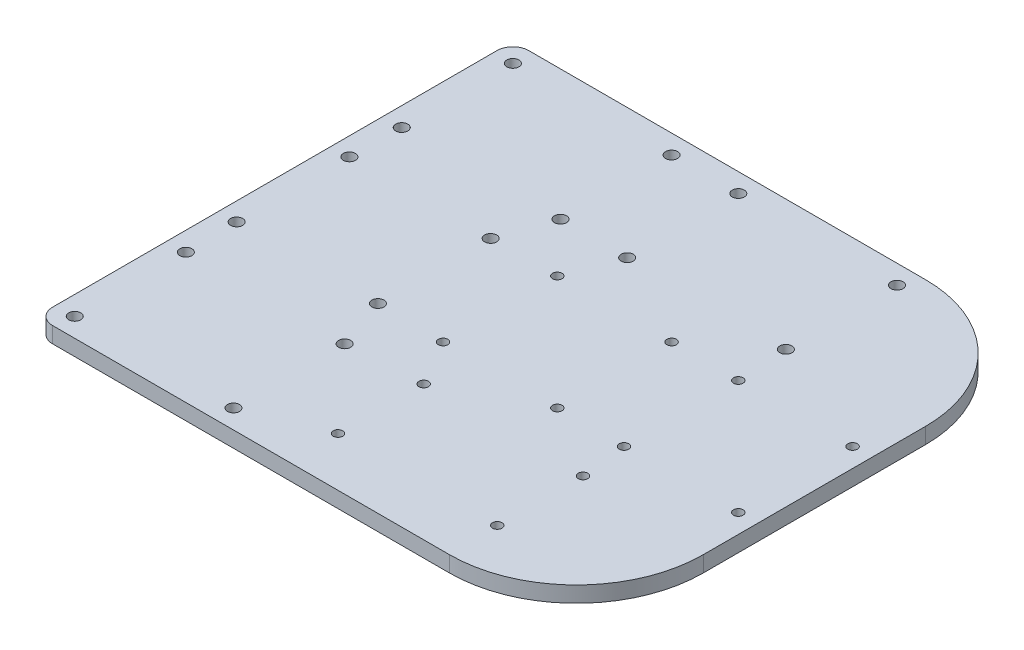
from build123d import *

# Parameters (mm, degrees)
SKETCH_1_W      = 170
SKETCH_1_H      = 150
SKETCH_1_R      = 1.5
SKETCH_1_R_2    = 1.9
EXTRUDE_1_DEPTH = 5
FILLET_1_R      = 5
FILLET_2_R      = 40


with BuildPart() as part:
    # 草图1 → 凸台-拉伸1 (new body)
    with BuildSketch(Plane(origin=(0, 0, 0), x_dir=(1, 0, 0), z_dir=(0, 1, 0))):
        with Locations((-4, 0)):
            Rectangle(SKETCH_1_W, SKETCH_1_H)
        with Locations((75, 18)):
            Circle(SKETCH_1_R, mode=Mode.SUBTRACT)
        with Locations((18, 18)):
            Circle(SKETCH_1_R, mode=Mode.SUBTRACT)
        with Locations((-83.25, 17.75)):
            Circle(SKETCH_1_R_2, mode=Mode.SUBTRACT)
        with Locations((-9.58, -59.5)):
            Circle(SKETCH_1_R, mode=Mode.SUBTRACT)
        with Locations((-83, 34)):
            Circle(SKETCH_1_R_2, mode=Mode.SUBTRACT)
        with Locations((-83, 69)):
            Circle(SKETCH_1_R_2, mode=Mode.SUBTRACT)
        with Locations((-33, 34)):
            Circle(SKETCH_1_R_2, mode=Mode.SUBTRACT)
        with Locations((-33, 69)):
            Circle(SKETCH_1_R_2, mode=Mode.SUBTRACT)
        with Locations((-12, 34)):
            Circle(SKETCH_1_R_2, mode=Mode.SUBTRACT)
        with Locations((-12, 69)):
            Circle(SKETCH_1_R_2, mode=Mode.SUBTRACT)
        with Locations((38, 69)):
            Circle(SKETCH_1_R_2, mode=Mode.SUBTRACT)
        with Locations((38, 34)):
            Circle(SKETCH_1_R_2, mode=Mode.SUBTRACT)
        with Locations((-38.75, 17.75)):
            Circle(SKETCH_1_R_2, mode=Mode.SUBTRACT)
        with Locations((-18, 18)):
            Circle(SKETCH_1_R, mode=Mode.SUBTRACT)
        with Locations((39, 18)):
            Circle(SKETCH_1_R, mode=Mode.SUBTRACT)
        with Locations((75, -18)):
            Circle(SKETCH_1_R, mode=Mode.SUBTRACT)
        with Locations((39, -18)):
            Circle(SKETCH_1_R, mode=Mode.SUBTRACT)
        with Locations((18, -18)):
            Circle(SKETCH_1_R, mode=Mode.SUBTRACT)
        with Locations((-18, -18)):
            Circle(SKETCH_1_R, mode=Mode.SUBTRACT)
        with Locations((-83, -69)):
            Circle(SKETCH_1_R_2, mode=Mode.SUBTRACT)
        with Locations((-33, -69)):
            Circle(SKETCH_1_R_2, mode=Mode.SUBTRACT)
        with Locations((-33, -34)):
            Circle(SKETCH_1_R_2, mode=Mode.SUBTRACT)
        with Locations((-83, -34)):
            Circle(SKETCH_1_R_2, mode=Mode.SUBTRACT)
        with Locations((-38.75, -17.75)):
            Circle(SKETCH_1_R_2, mode=Mode.SUBTRACT)
        with Locations((-83.25, -17.75)):
            Circle(SKETCH_1_R_2, mode=Mode.SUBTRACT)
        with Locations((40.58, -59.5)):
            Circle(SKETCH_1_R, mode=Mode.SUBTRACT)
        with Locations((40.58, -32.5)):
            Circle(SKETCH_1_R, mode=Mode.SUBTRACT)
        with Locations((-9.58, -32.5)):
            Circle(SKETCH_1_R, mode=Mode.SUBTRACT)
    extrude(amount=EXTRUDE_1_DEPTH)

    # 圆角1
    fillet_1_edges = [part.edges().sort_by_distance(p)[0] for p in [
        (-89, 2.5, -75),
        (-89, 2.5, 75),
    ]]
    fillet(fillet_1_edges, radius=FILLET_1_R)

    # 圆角2
    fillet_2_edges = [part.edges().sort_by_distance(p)[0] for p in [
        (81, 2.5, -75),
        (81, 2.5, 75),
    ]]
    fillet(fillet_2_edges, radius=FILLET_2_R)


solid = part.part
